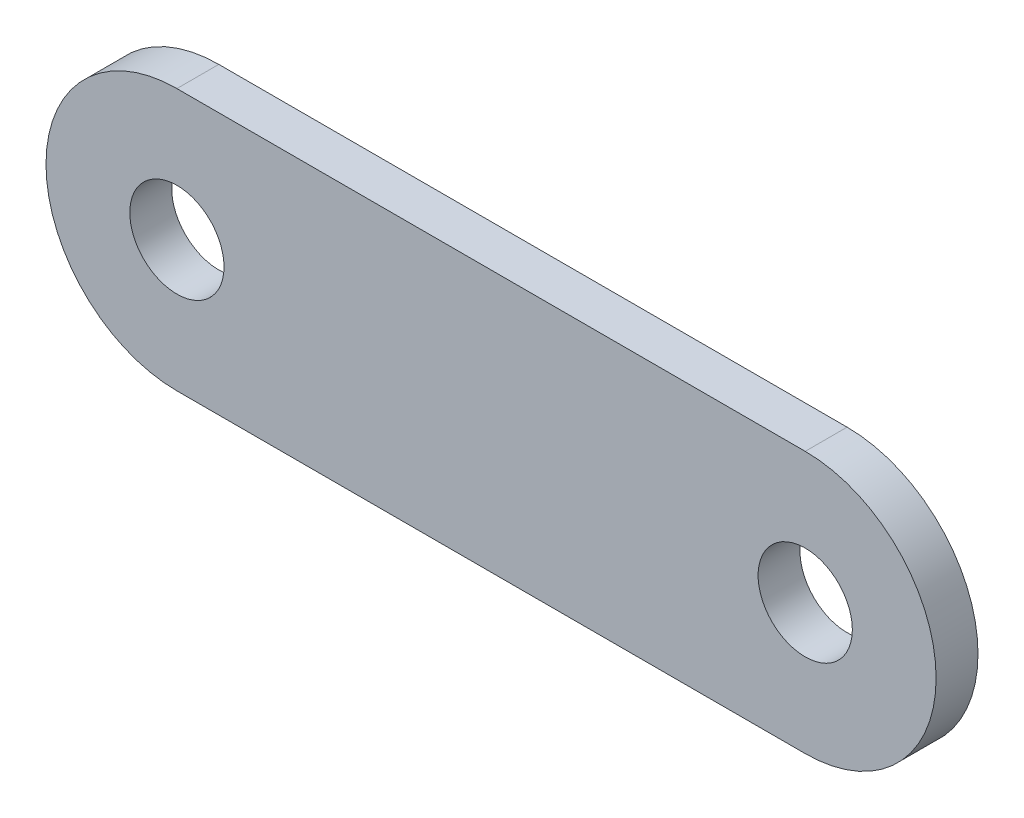
from build123d import *

# Parameters (mm, degrees)
SKIZZE1_R                       = 4.5
AUFSATZ_LINEAR_AUSTRAGEN1_DEPTH = 4


with BuildPart() as part:
    # Skizze1 → Aufsatz-Linear austragen1 (new body)
    with BuildSketch(Plane.XY):
        with BuildLine():
            Line((0, 12.5), (60, 12.5))
            ThreePointArc((60, 12.5), (72.5, 0), (60, -12.5))
            Line((60, -12.5), (0, -12.5))
            ThreePointArc((0, -12.5), (-12.5, 0), (0, 12.5))
        make_face()
        Circle(SKIZZE1_R, mode=Mode.SUBTRACT)
        with Locations((60, 0)):
            Circle(SKIZZE1_R, mode=Mode.SUBTRACT)
    extrude(amount=AUFSATZ_LINEAR_AUSTRAGEN1_DEPTH)


solid = part.part
